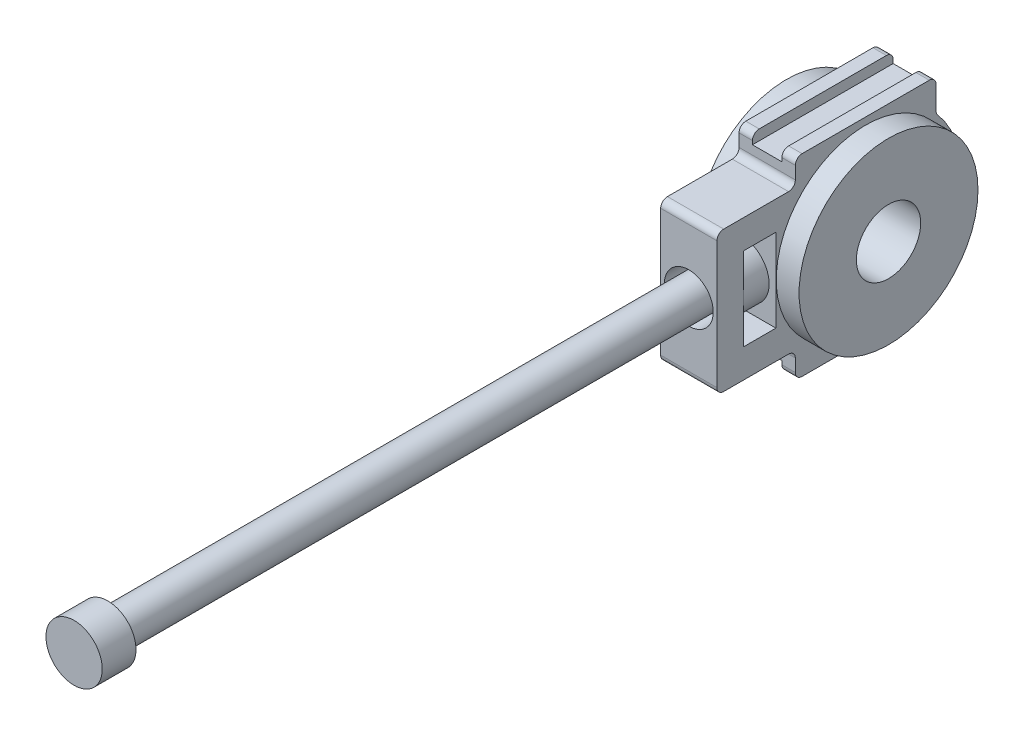
from build123d import *

# Parameters (mm, degrees)
BASE_EXTRUDE_DEPTH       = 4.1671875
SKETCH2_R                = 13.25
BOSS_EXTRUDE1_DEPTH      = 7.55
BOSS_EXTRUDE1_DEPTH_BACK = 7.55
SKETCH3_R                = 4.7625
SKETCH3_W                = 4.7625
SKETCH3_H                = 12.303125
CUT_EXTRUDE1_DEPTH       = 8.55
CUT_EXTRUDE1_DEPTH_BACK  = 8.55
SKETCH4_R                = 3.175
BOSS_EXTRUDE3_DEPTH      = 3.96875
SKETCH6_R                = 3.621484375
CUT_EXTRUDE2_DEPTH       = 3.96875
FILLET1_R                = 1
FILLET2_R                = 1
SKETCH7_W                = 4.365625
SKETCH7_H                = 1.537890625
CUT_EXTRUDE3_DEPTH       = 23.0265625
CUT_EXTRUDE3_DEPTH_BACK  = 15.0890625
BOSS_EXTRUDE4_START      = 1
SKETCH8_R                = 4.1671875
BOSS_EXTRUDE4_DEPTH      = 3.7625
SKETCH9_R                = 2.621484375
BOSS_EXTRUDE5_DEPTH      = 90
SKETCH10_R               = 4.1671875
BOSS_EXTRUDE6_DEPTH      = 5


with BuildPart() as part:
    # Sketch1 → Base-Extrude (new body, symmetric)
    with BuildSketch(Plane(origin=(0, 0, 0), x_dir=(0, 0, -1), z_dir=(1, 0, 0))):
        with BuildLine():
            Line((-10.41796875, 14.2875), (10.41796875, 14.2875))
            Line((10.41796875, 14.2875), (10.41796875, 9.485125685))
            ThreePointArc((10.41796875, 9.485125685), (14.0890625, 0), (10.41796875, -9.485125685))
            Line((10.41796875, -9.485125685), (10.41796875, -14.2875))
            Line((10.41796875, -14.2875), (-10.41796875, -14.2875))
            Line((-10.41796875, -14.2875), (-10.41796875, -10.41796875))
            Line((-10.41796875, -10.41796875), (-22.0265625, -10.41796875))
            Line((-22.0265625, -10.41796875), (-22.0265625, 10.41796875))
            Line((-22.0265625, 10.41796875), (-10.41796875, 10.41796875))
            Line((-10.41796875, 10.41796875), (-10.41796875, 14.2875))
        make_face()
    extrude(amount=BASE_EXTRUDE_DEPTH, both=True)

    # Sketch2 → Boss-Extrude1 (add, two sides)
    with BuildSketch(Plane(origin=(0, 0, 0), x_dir=(0, 0, -1), z_dir=(1, 0, 0))) as boss_extrude1_sk:
        Circle(SKETCH2_R)
    extrude(amount=BOSS_EXTRUDE1_DEPTH)
    extrude(boss_extrude1_sk.sketch, amount=-BOSS_EXTRUDE1_DEPTH_BACK)

    # Sketch3 → Cut-Extrude1 (cut, two sides)
    with BuildSketch(Plane(origin=(0, 0, 0), x_dir=(0, 0, -1), z_dir=(1, 0, 0))) as cut_extrude1_sk:
        Circle(SKETCH3_R)
        with Locations((-15.6765625, 0)):
            Rectangle(SKETCH3_W, SKETCH3_H)
    extrude(amount=CUT_EXTRUDE1_DEPTH, mode=Mode.SUBTRACT)
    extrude(cut_extrude1_sk.sketch, amount=-CUT_EXTRUDE1_DEPTH_BACK, mode=Mode.SUBTRACT)

    # Sketch4 → Boss-Extrude3 (add)
    with BuildSketch(Plane.XY.offset(22.0265625)):
        Circle(SKETCH4_R)
    extrude(amount=-BOSS_EXTRUDE3_DEPTH)

    # Sketch6 → Cut-Extrude2 (cut)
    with BuildSketch(Plane.XY.offset(22.0265625)):
        Circle(SKETCH6_R)
    extrude(amount=-CUT_EXTRUDE2_DEPTH, mode=Mode.SUBTRACT)

    # Fillet1
    fillet1_edges = [part.edges().sort_by_distance(p)[0] for p in [
        (0, 9.485125685, -10.41796875),
        (0, -9.485125685, -10.41796875),
        (0, -10.41796875, 10.41796875),
        (0, 10.41796875, 10.41796875),
    ]]
    fillet(fillet1_edges, radius=FILLET1_R)

    # Fillet2
    fillet2_edges = [part.edges().sort_by_distance(p)[0] for p in [
        (0, 14.2875, 10.41796875),
        (0, 14.2875, -10.41796875),
        (0, -14.2875, -10.41796875),
        (0, -14.2875, 10.41796875),
        (0, -10.41796875, 22.0265625),
        (0, 10.41796875, 22.0265625),
    ]]
    fillet(fillet2_edges, radius=FILLET2_R)

    # Sketch7 → Cut-Extrude3 (cut, two sides)
    with BuildSketch(Plane.XY) as cut_extrude3_sk:
        with Locations((0, 13.518554688)):
            Rectangle(SKETCH7_W, SKETCH7_H)
        with Locations((0, -13.518554688)):
            Rectangle(SKETCH7_W, SKETCH7_H)
    extrude(amount=CUT_EXTRUDE3_DEPTH, mode=Mode.SUBTRACT)
    extrude(cut_extrude3_sk.sketch, amount=-CUT_EXTRUDE3_DEPTH_BACK, mode=Mode.SUBTRACT)

    # Sketch8 → Boss-Extrude4 (add)
    with BuildSketch(Plane.XY.offset(13.2953125).offset(BOSS_EXTRUDE4_START)):
        Circle(SKETCH8_R)
    extrude(amount=BOSS_EXTRUDE4_DEPTH)

    # Sketch9 → Boss-Extrude5 (add)
    with BuildSketch(Plane.XY.offset(18.0578125)):
        Circle(SKETCH9_R)
    extrude(amount=BOSS_EXTRUDE5_DEPTH)

    # Sketch10 → Boss-Extrude6 (add)
    with BuildSketch(Plane.XY.offset(108.0578125)):
        Circle(SKETCH10_R)
    extrude(amount=BOSS_EXTRUDE6_DEPTH)


solid = part.part
